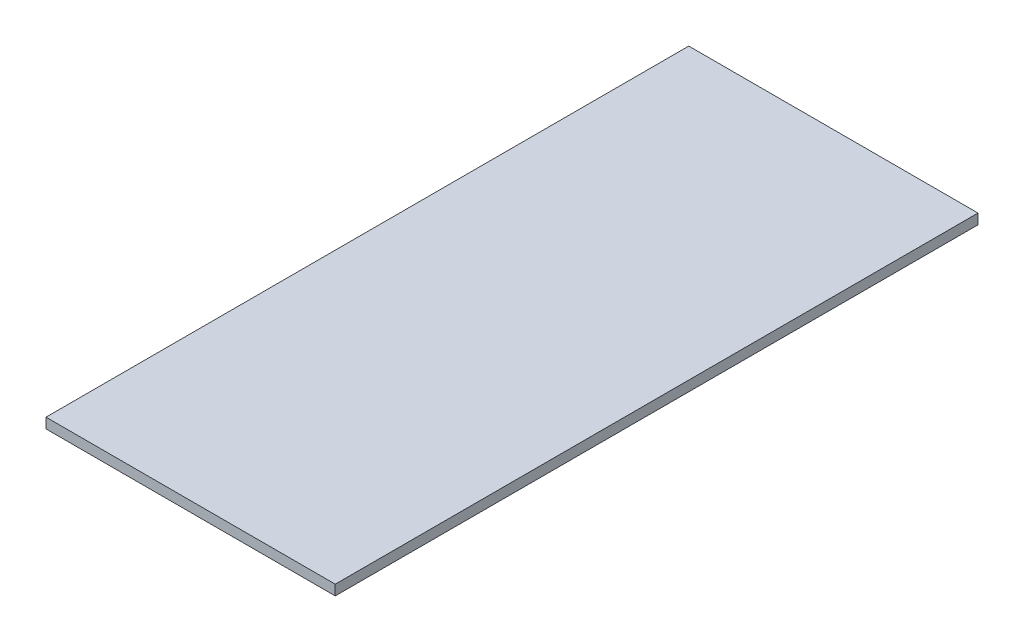
from build123d import *

# Parameters (mm, degrees)
SKETCH1_W           = 90
SKETCH1_H           = 200
BOSS_EXTRUDE1_DEPTH = 3.175


with BuildPart() as part:
    # Sketch1 → Boss-Extrude1 (new body)
    with BuildSketch(Plane(origin=(0, 0, 0), x_dir=(1, 0, 0), z_dir=(0, 1, 0))):
        with Locations((45, 100)):
            Rectangle(SKETCH1_W, SKETCH1_H)
    extrude(amount=BOSS_EXTRUDE1_DEPTH)


solid = part.part
